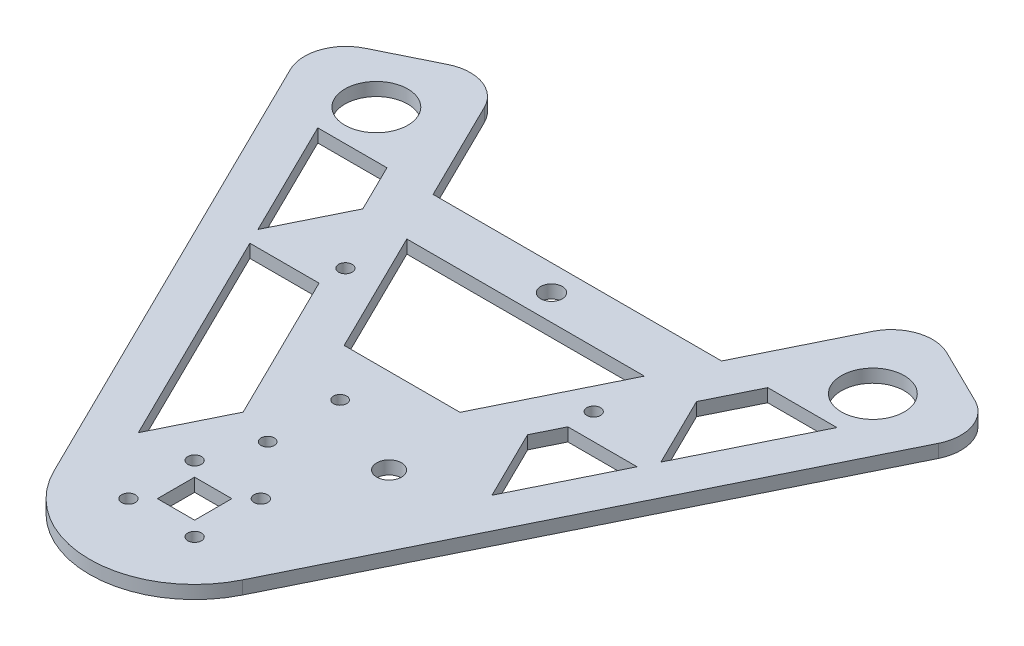
from build123d import *

# Parameters (mm, degrees)
SKETCH1_R               = 1.65
SKETCH1_R_2             = 1.6
SKETCH1_W               = 9
SKETCH1_H               = 9
SKETCH1_R_3             = 3
SKETCH1_R_4             = 7.6
SKETCH1_R_5             = 2.6
BOSS_EXTRUDE1_DEPTH     = 3.175
FILLET1_R               = 10
CUT_EXTRUDE1_DEPTH      = 1
CUT_EXTRUDE1_DEPTH_BACK = 4.175


with BuildPart() as part:
    # Sketch1 → Boss-Extrude1 (new body)
    with BuildSketch(Plane(origin=(0, 0, 0), x_dir=(1, 0, 0), z_dir=(0, 1, 0))):
        with BuildLine():
            Line((-51.31658538, 125.897213638), (-82.713802404, 110.430644428))
            Line((-82.713802404, 110.430644428), (-22.785408926, -11.224310227))
            ThreePointArc((-22.785408926, -11.224310227), (0, -25.4), (22.785408926, -11.224310227))
            Line((22.785408926, -11.224310227), (82.713802404, 110.430644428))
            Line((82.713802404, 110.430644428), (51.31658538, 125.897213638))
            Line((51.31658538, 125.897213638), (34.864798721, 92.5))
            Line((34.864798721, 92.5), (-34.864798721, 92.5))
            Line((-34.864798721, 92.5), (-51.31658538, 125.897213638))
        make_face()
        Polygon((-28.707179242, 80), (28.707179242, 80), (14, 50.144348614), (-14, 50.144348614), align=None, mode=Mode.SUBTRACT)
        with Locations((-8, -8)):
            Circle(SKETCH1_R, mode=Mode.SUBTRACT)
        with Locations((-8, 8)):
            Circle(SKETCH1_R, mode=Mode.SUBTRACT)
        with Locations((-3.1, 20.76053754)):
            Circle(SKETCH1_R_2, mode=Mode.SUBTRACT)
        with Locations((8, -8)):
            Circle(SKETCH1_R, mode=Mode.SUBTRACT)
        Rectangle(SKETCH1_W, SKETCH1_H, mode=Mode.SUBTRACT)
        with Locations((8, 8)):
            Circle(SKETCH1_R, mode=Mode.SUBTRACT)
        with Locations((17.5, 29.51053754)):
            Circle(SKETCH1_R_3, mode=Mode.SUBTRACT)
        with Locations((-30, 66.453060464)):
            Circle(SKETCH1_R, mode=Mode.SUBTRACT)
        with Locations((-60, 103.923048454)):
            Circle(SKETCH1_R_4, mode=Mode.SUBTRACT)
        with Locations((30, 66.453060464)):
            Circle(SKETCH1_R, mode=Mode.SUBTRACT)
        with Locations((60, 103.923048454)):
            Circle(SKETCH1_R_4, mode=Mode.SUBTRACT)
        with Locations((0, 86.25)):
            Circle(SKETCH1_R_5, mode=Mode.SUBTRACT)
        with Locations((-3.1, 38.26053754)):
            Circle(SKETCH1_R_2, mode=Mode.SUBTRACT)
    extrude(amount=BOSS_EXTRUDE1_DEPTH)

    # Fillet1
    fillet1_edges = [part.edges().sort_by_distance(p)[0] for p in [
        (51.31658538, 1.5875, -125.897213638),
        (82.713802404, 1.5875, -110.430644428),
        (-82.713802404, 1.5875, -110.430644428),
        (-51.31658538, 1.5875, -125.897213638),
    ]]
    fillet(fillet1_edges, radius=FILLET1_R)

    # Sketch2 → Cut-Extrude1 (cut, two sides)
    with BuildSketch(Plane(origin=(0, 3.175, 0), x_dir=(1, 0, 0), z_dir=(0, 1, 0))) as cut_extrude1_sk:
        Polygon((-46.79480762, 60.144348614), (-30.073580398, 60.144348614), (-12.254779912, 23.972089701), (-20.615393523, 7), align=None)
        Polygon((-62.733510758, 92.5), (-48.694138346, 64), (-40.333524735, 80.972089701), (-46.012283536, 92.5), align=None)
        Polygon((30.073580398, 60.144348614), (46.79480762, 60.144348614), (35.218483, 36.644348614), (26.857869389, 53.616438315), align=None)
        Polygon((46.012283536, 92.5), (62.733510758, 92.5), (48.694138346, 64), (40.333524735, 80.972089701), align=None)
    extrude(amount=CUT_EXTRUDE1_DEPTH, mode=Mode.SUBTRACT)
    extrude(cut_extrude1_sk.sketch, amount=-CUT_EXTRUDE1_DEPTH_BACK, mode=Mode.SUBTRACT)


solid = part.part
